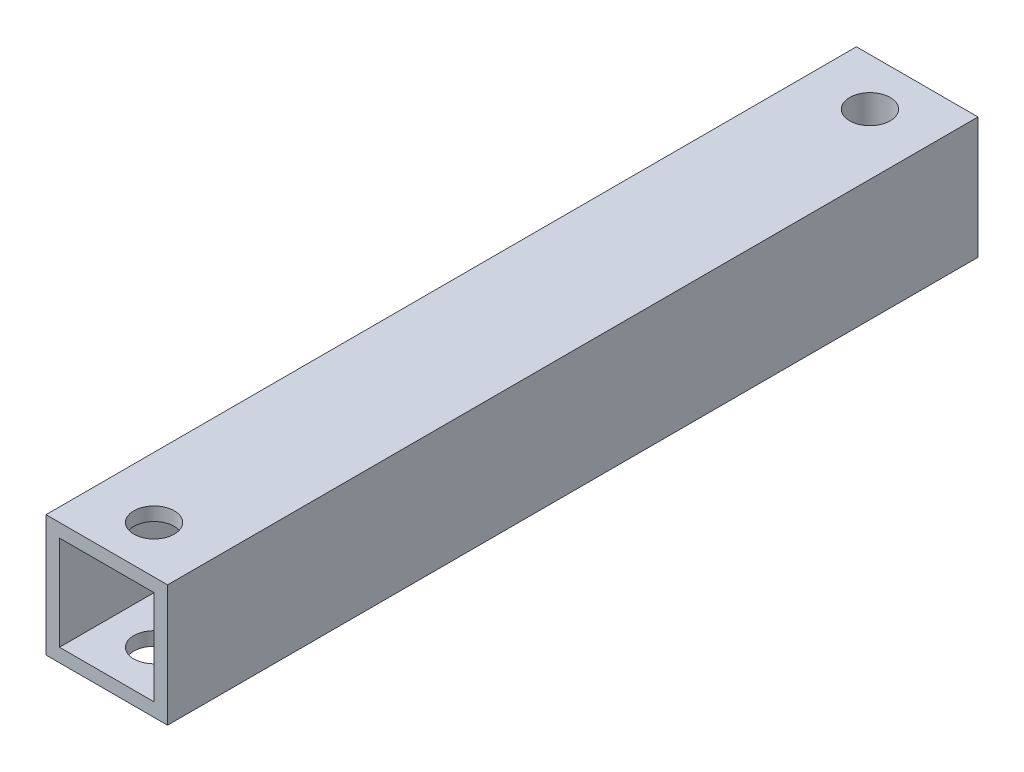
from build123d import *

# Parameters (mm, degrees)
SKETCH_1_W          = 9
SKETCH_1_H          = 9
EXTRUDE_1_DEPTH     = 60
SKETCH_2_W          = 7
SKETCH_2_H          = 7
CUT_EXTRUDE_1_DEPTH = 56
SKETCH_3_R          = 1.5
CUT_EXTRUDE_2_DEPTH = 56


with BuildPart() as part:
    # ｽｹｯﾁ1 → ﾎﾞｽ - 押し出し1 (new body)
    with BuildSketch(Plane.XY):
        Rectangle(SKETCH_1_W, SKETCH_1_H)
    extrude(amount=EXTRUDE_1_DEPTH)

    # ｽｹｯﾁ2 → ｶｯﾄ - 押し出し1 (cut)
    with BuildSketch(Plane.XY.offset(60)):
        Rectangle(SKETCH_2_W, SKETCH_2_H)
    extrude(amount=-CUT_EXTRUDE_1_DEPTH, mode=Mode.SUBTRACT)

    # ｽｹｯﾁ3 → ｶｯﾄ - 押し出し2 (cut)
    with BuildSketch(Plane(origin=(0, 4.5, 0), x_dir=(1, 0, 0), z_dir=(0, 1, 0))):
        with Locations((0, -3.5)):
            Circle(SKETCH_3_R)
        with Locations((0, -56.5)):
            Circle(SKETCH_3_R)
    extrude(amount=-CUT_EXTRUDE_2_DEPTH, mode=Mode.SUBTRACT)


solid = part.part
